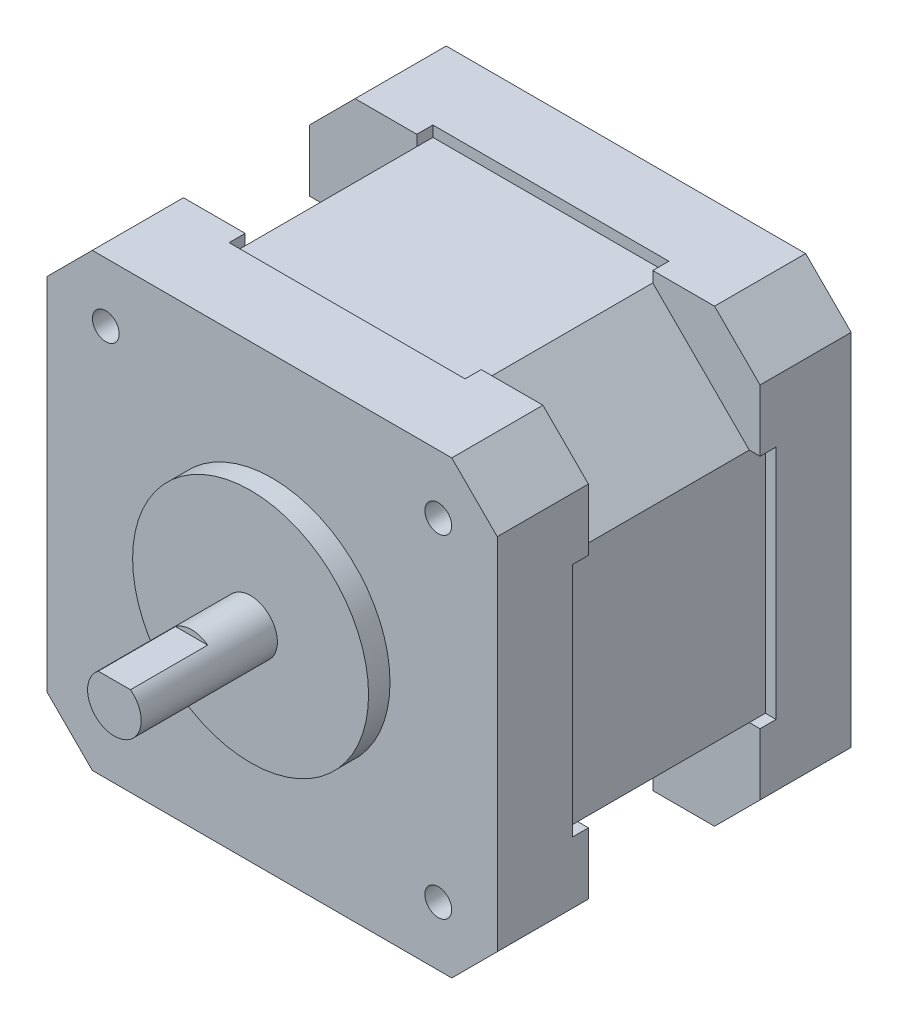
from build123d import *

# Parameters (mm, degrees)
BOSS_EXTRUDE1_DEPTH            = 33
M3X0_5_TAPPED_HOLE1_AT_2_COUNT = 2
M3X0_5_TAPPED_HOLE1_AT_2_PITCH = 43.840620434
M3X0_5_TAPPED_HOLE1_AT_3_COUNT = 2
M3X0_5_TAPPED_HOLE1_AT_3_PITCH = 31
M3X0_5_TAPPED_HOLE1_AT_4_COUNT = 2
M3X0_5_TAPPED_HOLE1_AT_4_PITCH = 31
SKETCH4_OUTSIDE_W              = 57.59
SKETCH4_OUTSIDE_H              = 57.59
CUT_EXTRUDE1_DEPTH             = 8
SKETCH5_W                      = 19
SKETCH5_H                      = 22
CUT_EXTRUDE2_DEPTH             = 1
CIRPATTERN1_COUNT              = 4
SKETCH7_R                      = 11
BOSS_EXTRUDE2_DEPTH            = 2
SKETCH8_R                      = 2.5
BOSS_EXTRUDE3_DEPTH            = 12.7
CUT_EXTRUDE3_DEPTH             = 7.2


with BuildPart() as part:
    # Sketch1 → Boss-Extrude1 (new body)
    with BuildSketch(Plane.XY):
        Polygon((16.757359313, 21), (-16.757359313, 21), (-21, 16.757359313), (-21, -16.757359313), (-16.757359313, -21), (16.757359313, -21), (21, -16.757359313), (21, 16.757359313), align=None)
    extrude(amount=-BOSS_EXTRUDE1_DEPTH)

    # Sketch2 → M3x0.5 Tapped Hole1 (revolve, cut)
    with BuildSketch(Plane(origin=(-15.5, 15.5, 0), x_dir=(0, -1, 0), z_dir=(1, 0, 0))):
        Polygon((0, 0), (0, 8.251075774), (1.25, 7.5), (1.25, 0), align=None)
    m3x0_5_tapped_hole1 = revolve(axis=Axis((-15.5, 15.5, 6.35), (0, 0, -1)), mode=Mode.SUBTRACT)

    # M3x0.5 Tapped Hole1 at 2: M3x0.5 Tapped Hole1 ×2
    with Locations(*[Vector(0.707106781, -0.707106781, 0) * (i * M3X0_5_TAPPED_HOLE1_AT_2_PITCH) for i in range(1, M3X0_5_TAPPED_HOLE1_AT_2_COUNT)]):
        add(m3x0_5_tapped_hole1, mode=Mode.SUBTRACT)

    # M3x0.5 Tapped Hole1 at 3: M3x0.5 Tapped Hole1 ×2
    with Locations(*[(i * M3X0_5_TAPPED_HOLE1_AT_3_PITCH, 0, 0) for i in range(1, M3X0_5_TAPPED_HOLE1_AT_3_COUNT)]):
        add(m3x0_5_tapped_hole1, mode=Mode.SUBTRACT)

    # M3x0.5 Tapped Hole1 at 4: M3x0.5 Tapped Hole1 ×2
    with Locations(*[(0, -i * M3X0_5_TAPPED_HOLE1_AT_4_PITCH, 0) for i in range(1, M3X0_5_TAPPED_HOLE1_AT_4_COUNT)]):
        add(m3x0_5_tapped_hole1, mode=Mode.SUBTRACT)

    # Sketch4 outside → Cut-Extrude1 (cut, symmetric)
    with BuildSketch(Plane.XY.offset(-16.5)):
        Rectangle(SKETCH4_OUTSIDE_W, SKETCH4_OUTSIDE_H)
        Polygon((11, -20), (-11, -20), (-20, -11), (-20, 11), (-11, 20), (11, 20), (20, 11), (20, -11), align=None, mode=Mode.SUBTRACT)
    extrude(amount=CUT_EXTRUDE1_DEPTH, both=True, mode=Mode.SUBTRACT)

    # Sketch5 → Cut-Extrude2 (cut)
    with BuildSketch(Plane(origin=(21, 0, 0), x_dir=(0, 0, -1), z_dir=(1, 0, 0))):
        with Locations((16.5, 0)):
            Rectangle(SKETCH5_W, SKETCH5_H)
    cut_extrude2 = extrude(amount=-CUT_EXTRUDE2_DEPTH, mode=Mode.SUBTRACT)

    # CirPattern1: Cut-Extrude2 ×4 about axis
    cirpattern1_axis = Axis((0, 0, 0), (0, 0, 1))
    for i in range(1, CIRPATTERN1_COUNT):
        add(cut_extrude2.rotate(cirpattern1_axis, i * 360 / CIRPATTERN1_COUNT), mode=Mode.SUBTRACT)

    # Sketch7 → Boss-Extrude2 (add)
    with BuildSketch(Plane.XY):
        Circle(SKETCH7_R)
    extrude(amount=BOSS_EXTRUDE2_DEPTH)

    # Sketch8 → Boss-Extrude3 (add)
    with BuildSketch(Plane.XY.offset(2)):
        Circle(SKETCH8_R)
    extrude(amount=BOSS_EXTRUDE3_DEPTH)

    # Sketch9 → Cut-Extrude3 (cut)
    with BuildSketch(Plane.XY.offset(14.7)):
        with BuildLine():
            Line((-1.5, 2), (1.5, 2))
            ThreePointArc((1.5, 2), (0, 2.5), (-1.5, 2))
        make_face()
    extrude(amount=-CUT_EXTRUDE3_DEPTH, mode=Mode.SUBTRACT)

    # Mirror1: M3x0.5 Tapped Hole1 across plane
    add(m3x0_5_tapped_hole1.mirror(Plane.XY.offset(-16.5)), mode=Mode.SUBTRACT)

    # Mirror1 copy 1 sketch → Mirror1 copy 1 (revolve, cut)
    with BuildSketch(Plane(origin=(15.5, -15.5, -33), x_dir=(0, -1, 0), z_dir=(1, 0, 0))):
        Polygon((0, 0), (0, -8.251075774), (1.25, -7.5), (1.25, 0), align=None)
    revolve(axis=Axis((15.5, -15.5, -39.35), (0, 0, -1)), mode=Mode.SUBTRACT)

    # Mirror1 copy 2 sketch → Mirror1 copy 2 (revolve, cut)
    with BuildSketch(Plane(origin=(15.5, 15.5, -33), x_dir=(0, -1, 0), z_dir=(1, 0, 0))):
        Polygon((0, 0), (0, -8.251075774), (1.25, -7.5), (1.25, 0), align=None)
    revolve(axis=Axis((15.5, 15.5, -39.35), (0, 0, -1)), mode=Mode.SUBTRACT)

    # Mirror1 copy 3 sketch → Mirror1 copy 3 (revolve, cut)
    with BuildSketch(Plane(origin=(-15.5, -15.5, -33), x_dir=(0, -1, 0), z_dir=(1, 0, 0))):
        Polygon((0, 0), (0, -8.251075774), (1.25, -7.5), (1.25, 0), align=None)
    revolve(axis=Axis((-15.5, -15.5, -39.35), (0, 0, -1)), mode=Mode.SUBTRACT)


solid = part.part
